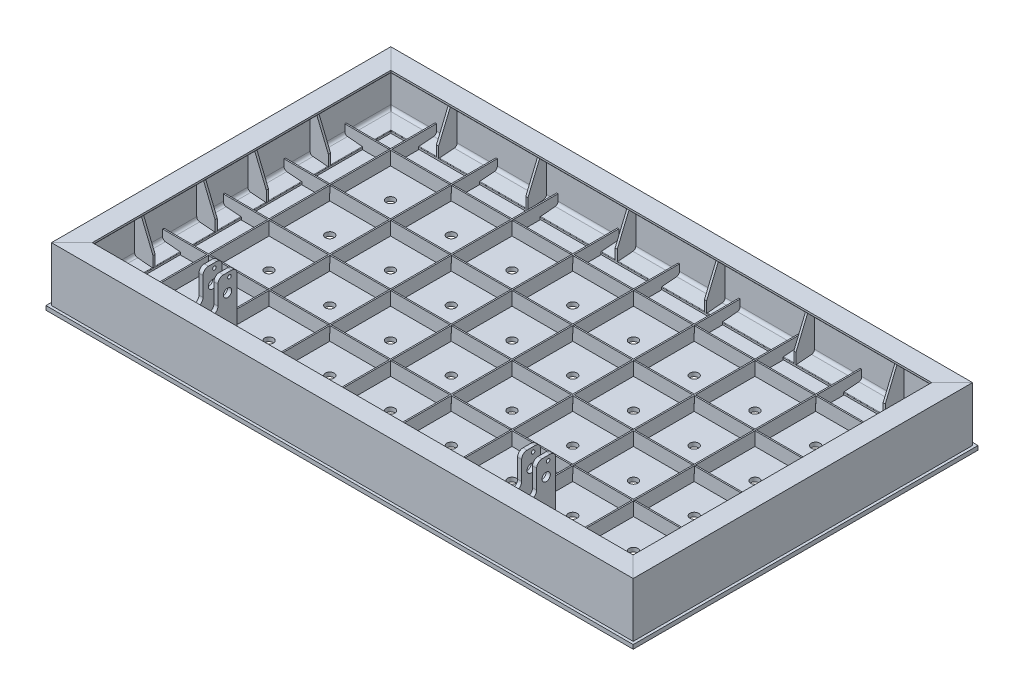
from build123d import *

# Parameters (mm, degrees)
UPN_200X75_SLDLFP_1_DEPTH      = 1660.600093633
UPN_200X75_SLDLFP_1_DEPTH_BACK = 414.600093633
UPN_200X75_SLDLFP_1_2_DEPTH    = 2965.200187266
UPN_200X75_SLDLFP_1_3_DEPTH    = 2075.200187266
UPN_200X75_SLDLFP_1_4_DEPTH    = 2965.200187266
ESQUISSE14_W                   = 5
ESQUISSE14_H                   = 50
GRAND_PLAT_50_5_DEPTH          = 2115
GRAND_PLAT_50_5_2_DEPTH        = 2115
GRAND_PLAT_50_5_3_DEPTH        = 2115
GRAND_PLAT_50_5_4_DEPTH        = 2115
GRAND_PLAT_50_5_5_DEPTH        = 2115
ENL_V_MAT_EXTRU_1_DEPTH        = 2115
ENL_V_MAT_EXTRU_1_DEPTH_BACK   = 2115
ENL_V_MAT_EXTRU_2_DEPTH        = 2115
ENL_V_MAT_EXTRU_2_DEPTH_BACK   = 2115
ESQUISSE17_W                   = 5
ESQUISSE17_H                   = 50
PITIT_PLAT_DE_50_5_DEPTH       = 1225
PITIT_PLAT_DE_50_5_2_DEPTH     = 1225
PITIT_PLAT_DE_50_5_3_DEPTH     = 1225
PITIT_PLAT_DE_50_5_4_DEPTH     = 1225
PITIT_PLAT_DE_50_5_5_DEPTH     = 1225
PITIT_PLAT_DE_50_5_6_DEPTH     = 1225
PITIT_PLAT_DE_50_5_7_DEPTH     = 1225
PITIT_PLAT_DE_50_5_8_DEPTH     = 1225
PITIT_PLAT_DE_50_5_9_DEPTH     = 1225
ENL_V_MAT_EXTRU_3_DEPTH        = 1225
ENL_V_MAT_EXTRU_3_DEPTH_BACK   = 1575
ESQUISSE19_W                   = 6
ESQUISSE19_H                   = 26
ENL_V_MAT_EXTRU_4_DEPTH        = 1575
ENL_V_MAT_EXTRU_4_DEPTH_BACK   = 1575
ESQUISSE20_W                   = 6
ESQUISSE20_H                   = 26
ENL_V_MAT_EXTRU_5_DEPTH        = 1575
ENL_V_MAT_EXTRU_5_DEPTH_BACK   = 1575
ESQUISSE21_W                   = 2156
ESQUISSE21_H                   = 1266
BOSS_EXTRU_4_DEPTH             = 15
ESQUISSE22_R                   = 16
ENL_V_MAT_EXTRU_6_DEPTH        = 15
BOSS_EXTRU_5_DEPTH             = 8
R_P_TITION_LIN_AIRE1_COUNT     = 3
R_P_TITION_LIN_AIRE1_PITCH     = 328
R_P_TITION_LIN_AIRE2_COUNT     = 4
R_P_TITION_LIN_AIRE2_PITCH     = 328
BOSS_EXTRU_7_DEPTH             = 8
R_P_TITION_LIN_AIRE6_COUNT     = 2
R_P_TITION_LIN_AIRE6_PITCH     = 228
ESQUISSE27_R                   = 15.25
ESQUISSE27_R_2                 = 6.5
BOSS_EXTRU_8_DEPTH             = 15
R_P_TITION_LIN_AIRE7_COUNT     = 2
R_P_TITION_LIN_AIRE7_PITCH     = 55


with BuildPart() as part:
    # Esquisse11 → Upn 200X75 SLDLFP(1) (new, two sides)
    with BuildSketch(Plane(origin=(1068, -200, 623), x_dir=(-1, 0, 0), z_dir=(0, 0, -1))) as upn_200x75_sldlfp_1_sk:
        with BuildLine():
            Line((0, 0), (75, 0))
            Line((75, 0), (75, 6.574620799))
            ThreePointArc((75, 6.574620799), (74.471012242, 7.929656954), (73.163877017, 8.567895572))
            Line((73.163877017, 8.567895572), (19.057707151, 13.016232475))
            ThreePointArc((19.057707151, 13.016232475), (11.541679606, 16.686104529), (8.5, 24.477562424))
            Line((8.5, 24.477562424), (8.5, 175.522437576))
            ThreePointArc((8.5, 175.522437576), (11.541679606, 183.313895471), (19.057707151, 186.983767525))
            Line((19.057707151, 186.983767525), (73.163877017, 191.432104428))
            ThreePointArc((73.163877017, 191.432104428), (74.471012242, 192.070343046), (75, 193.425379201))
            Line((75, 193.425379201), (75, 200))
            Line((75, 200), (0, 200))
            Line((0, 200), (0, 0))
        make_face()
    extrude(amount=UPN_200X75_SLDLFP_1_DEPTH)
    extrude(upn_200x75_sldlfp_1_sk.sketch, amount=-UPN_200X75_SLDLFP_1_DEPTH_BACK)

    # Upn 200X75 SLDLFP(1) mitre 1
    split(bisect_by=Plane(origin=(1068, 0, 623), x_dir=(0, 1, 0), z_dir=(0.707106781, 0, -0.707106781)), keep=Keep.TOP)

    # Upn 200X75 SLDLFP(1) mitre 2
    split(bisect_by=Plane(origin=(1068, 0, -623), x_dir=(0, 1, 0), z_dir=(0.707106781, 0, 0.707106781)), keep=Keep.TOP)


with BuildPart() as body_2:
    # Esquisse11 on segment 2 (carried to segment 2) → Upn 200X75 SLDLFP_1 2 (new body)
    with BuildSketch(Plane(origin=(1482.600093633, -200, -623), x_dir=(0, 0, 1), z_dir=(-1, 0, 0))):
        with BuildLine():
            Line((0, 0), (75, 0))
            Line((75, 0), (75, 6.574620799))
            ThreePointArc((75, 6.574620799), (74.471012242, 7.929656954), (73.163877017, 8.567895572))
            Line((73.163877017, 8.567895572), (19.057707151, 13.016232475))
            ThreePointArc((19.057707151, 13.016232475), (11.541679606, 16.686104529), (8.5, 24.477562424))
            Line((8.5, 24.477562424), (8.5, 175.522437576))
            ThreePointArc((8.5, 175.522437576), (11.541679606, 183.313895471), (19.057707151, 186.983767525))
            Line((19.057707151, 186.983767525), (73.163877017, 191.432104428))
            ThreePointArc((73.163877017, 191.432104428), (74.471012242, 192.070343046), (75, 193.425379201))
            Line((75, 193.425379201), (75, 200))
            Line((75, 200), (0, 200))
            Line((0, 200), (0, 0))
        make_face()
    extrude(amount=UPN_200X75_SLDLFP_1_2_DEPTH)

    # Upn 200X75 SLDLFP_1 2 mitre 1
    split(bisect_by=Plane(origin=(-1068, 0, -623), x_dir=(0, 1, 0), z_dir=(0.707106781, 0, -0.707106781)), keep=Keep.TOP)

    # Upn 200X75 SLDLFP_1 2 mitre 2
    split(bisect_by=Plane(origin=(1068, 0, -623), x_dir=(0, -1, 0), z_dir=(-0.707106781, 0, -0.707106781)), keep=Keep.TOP)


with BuildPart() as body_3:
    # Esquisse11 on segment 3 (carried to segment 3) → Upn 200X75 SLDLFP_1 3 (new body)
    with BuildSketch(Plane(origin=(-1068, -200, -1037.600093633), x_dir=(1, 0, 0), z_dir=(0, 0, 1))):
        with BuildLine():
            Line((0, 0), (75, 0))
            Line((75, 0), (75, 6.574620799))
            ThreePointArc((75, 6.574620799), (74.471012242, 7.929656954), (73.163877017, 8.567895572))
            Line((73.163877017, 8.567895572), (19.057707151, 13.016232475))
            ThreePointArc((19.057707151, 13.016232475), (11.541679606, 16.686104529), (8.5, 24.477562424))
            Line((8.5, 24.477562424), (8.5, 175.522437576))
            ThreePointArc((8.5, 175.522437576), (11.541679606, 183.313895471), (19.057707151, 186.983767525))
            Line((19.057707151, 186.983767525), (73.163877017, 191.432104428))
            ThreePointArc((73.163877017, 191.432104428), (74.471012242, 192.070343046), (75, 193.425379201))
            Line((75, 193.425379201), (75, 200))
            Line((75, 200), (0, 200))
            Line((0, 200), (0, 0))
        make_face()
    extrude(amount=UPN_200X75_SLDLFP_1_3_DEPTH)

    # Upn 200X75 SLDLFP_1 3 mitre 1
    split(bisect_by=Plane(origin=(-1068, 0, 623), x_dir=(0, -1, 0), z_dir=(-0.707106781, 0, -0.707106781)), keep=Keep.TOP)

    # Upn 200X75 SLDLFP_1 3 mitre 2
    split(bisect_by=Plane(origin=(-1068, 0, -623), x_dir=(0, -1, 0), z_dir=(-0.707106781, 0, 0.707106781)), keep=Keep.TOP)


with BuildPart() as body_4:
    # Esquisse11 on segment 4 (carried to segment 4) → Upn 200X75 SLDLFP_1 4 (new body)
    with BuildSketch(Plane(origin=(-1482.600093633, -200, 623), x_dir=(0, 0, -1), z_dir=(1, 0, 0))):
        with BuildLine():
            Line((0, 0), (75, 0))
            Line((75, 0), (75, 6.574620799))
            ThreePointArc((75, 6.574620799), (74.471012242, 7.929656954), (73.163877017, 8.567895572))
            Line((73.163877017, 8.567895572), (19.057707151, 13.016232475))
            ThreePointArc((19.057707151, 13.016232475), (11.541679606, 16.686104529), (8.5, 24.477562424))
            Line((8.5, 24.477562424), (8.5, 175.522437576))
            ThreePointArc((8.5, 175.522437576), (11.541679606, 183.313895471), (19.057707151, 186.983767525))
            Line((19.057707151, 186.983767525), (73.163877017, 191.432104428))
            ThreePointArc((73.163877017, 191.432104428), (74.471012242, 192.070343046), (75, 193.425379201))
            Line((75, 193.425379201), (75, 200))
            Line((75, 200), (0, 200))
            Line((0, 200), (0, 0))
        make_face()
    extrude(amount=UPN_200X75_SLDLFP_1_4_DEPTH)

    # Upn 200X75 SLDLFP_1 4 mitre 1
    split(bisect_by=Plane(origin=(-1068, 0, 623), x_dir=(0, 1, 0), z_dir=(0.707106781, 0, 0.707106781)), keep=Keep.TOP)

    # Upn 200X75 SLDLFP_1 4 mitre 2
    split(bisect_by=Plane(origin=(1068, 0, 623), x_dir=(0, -1, 0), z_dir=(-0.707106781, 0, 0.707106781)), keep=Keep.TOP)


with BuildPart() as body_5:
    # Esquisse14 → grand plat 50/5 (new body)
    with BuildSketch(Plane(origin=(-1057.5, 0, 0), x_dir=(0, 0, -1), z_dir=(1, 0, 0))):
        with Locations((446, -175)):
            Rectangle(ESQUISSE14_W, ESQUISSE14_H)
    extrude(amount=GRAND_PLAT_50_5_DEPTH)


with BuildPart() as body_6:
    # Esquisse14 → grand plat 50_5 2 (new body)
    with BuildSketch(Plane(origin=(-1057.5, 0, 0), x_dir=(0, 0, -1), z_dir=(1, 0, 0))):
        with Locations((0, -175)):
            Rectangle(ESQUISSE14_W, ESQUISSE14_H)
    extrude(amount=GRAND_PLAT_50_5_2_DEPTH)


with BuildPart() as body_7:
    # Esquisse14 → grand plat 50_5 3 (new body)
    with BuildSketch(Plane(origin=(-1057.5, 0, 0), x_dir=(0, 0, -1), z_dir=(1, 0, 0))):
        with Locations((-223, -175)):
            Rectangle(ESQUISSE14_W, ESQUISSE14_H)
    extrude(amount=GRAND_PLAT_50_5_3_DEPTH)


with BuildPart() as body_8:
    # Esquisse14 → grand plat 50_5 4 (new body)
    with BuildSketch(Plane(origin=(-1057.5, 0, 0), x_dir=(0, 0, -1), z_dir=(1, 0, 0))):
        with Locations((-446, -175)):
            Rectangle(ESQUISSE14_W, ESQUISSE14_H)
    extrude(amount=GRAND_PLAT_50_5_4_DEPTH)


with BuildPart() as body_9:
    # Esquisse14 → grand plat 50_5 5 (new body)
    with BuildSketch(Plane(origin=(-1057.5, 0, 0), x_dir=(0, 0, -1), z_dir=(1, 0, 0))):
        with Locations((223, -175)):
            Rectangle(ESQUISSE14_W, ESQUISSE14_H)
    extrude(amount=GRAND_PLAT_50_5_5_DEPTH)


with BuildPart() as enl_v_mat_extru_1_tool:
    # Esquisse15 → Enlèv. mat.-Extru.1 (new, two sides)
    with BuildSketch(Plane(origin=(0, 0, -2.5), x_dir=(-1, 0, 0), z_dir=(0, 0, -1))) as enl_v_mat_extru_1_sk:
        with BuildLine():
            Line((991.5, -200), (991.5, -190.201322727))
            Line((991.5, -190.201322727), (1046.942292849, -185.643136519))
            ThreePointArc((1046.942292849, -185.643136519), (1054.458320394, -181.973264464), (1057.5, -174.18180657))
            Line((1057.5, -174.18180657), (1057.5, -200))
            Line((1057.5, -200), (991.5, -200))
        make_face()
    extrude(amount=ENL_V_MAT_EXTRU_1_DEPTH)
    extrude(enl_v_mat_extru_1_sk.sketch, amount=-ENL_V_MAT_EXTRU_1_DEPTH_BACK)


with BuildPart() as body_8_1:
    add(body_8.part)

    # Enlèv. mat.-Extru.1: cut by enl_v_mat_extru_1_tool
    add(enl_v_mat_extru_1_tool.part, mode=Mode.SUBTRACT)


with BuildPart() as body_7_1:
    add(body_7.part)

    # Enlèv. mat.-Extru.1: cut by enl_v_mat_extru_1_tool
    add(enl_v_mat_extru_1_tool.part, mode=Mode.SUBTRACT)


with BuildPart() as body_6_1:
    add(body_6.part)

    # Enlèv. mat.-Extru.1: cut by enl_v_mat_extru_1_tool
    add(enl_v_mat_extru_1_tool.part, mode=Mode.SUBTRACT)


with BuildPart() as body_9_1:
    add(body_9.part)

    # Enlèv. mat.-Extru.1: cut by enl_v_mat_extru_1_tool
    add(enl_v_mat_extru_1_tool.part, mode=Mode.SUBTRACT)


with BuildPart() as body_5_1:
    add(body_5.part)

    # Enlèv. mat.-Extru.1: cut by enl_v_mat_extru_1_tool
    add(enl_v_mat_extru_1_tool.part, mode=Mode.SUBTRACT)


with BuildPart() as enl_v_mat_extru_2_tool:
    # Esquisse16 → Enlèv. mat.-Extru.2 (new, two sides)
    with BuildSketch(Plane(origin=(0, 0, 220.5), x_dir=(-1, 0, 0), z_dir=(0, 0, -1))) as enl_v_mat_extru_2_sk:
        with BuildLine():
            Line((-991.5, -200), (-991.5, -190.201322727))
            Line((-991.5, -190.201322727), (-1046.942292849, -185.643136519))
            ThreePointArc((-1046.942292849, -185.643136519), (-1054.458320394, -181.973264464), (-1057.5, -174.18180657))
            Line((-1057.5, -174.18180657), (-1057.5, -200))
            Line((-1057.5, -200), (-991.5, -200))
        make_face()
    extrude(amount=ENL_V_MAT_EXTRU_2_DEPTH)
    extrude(enl_v_mat_extru_2_sk.sketch, amount=-ENL_V_MAT_EXTRU_2_DEPTH_BACK)


with BuildPart() as body_8_2:
    add(body_8_1.part)

    # Enlèv. mat.-Extru.2: cut by enl_v_mat_extru_2_tool
    add(enl_v_mat_extru_2_tool.part, mode=Mode.SUBTRACT)


with BuildPart() as body_7_2:
    add(body_7_1.part)

    # Enlèv. mat.-Extru.2: cut by enl_v_mat_extru_2_tool
    add(enl_v_mat_extru_2_tool.part, mode=Mode.SUBTRACT)


with BuildPart() as body_6_2:
    add(body_6_1.part)

    # Enlèv. mat.-Extru.2: cut by enl_v_mat_extru_2_tool
    add(enl_v_mat_extru_2_tool.part, mode=Mode.SUBTRACT)


with BuildPart() as body_9_2:
    add(body_9_1.part)

    # Enlèv. mat.-Extru.2: cut by enl_v_mat_extru_2_tool
    add(enl_v_mat_extru_2_tool.part, mode=Mode.SUBTRACT)


with BuildPart() as body_5_2:
    add(body_5_1.part)

    # Enlèv. mat.-Extru.2: cut by enl_v_mat_extru_2_tool
    add(enl_v_mat_extru_2_tool.part, mode=Mode.SUBTRACT)


with BuildPart() as body_10:
    # Esquisse17 → pitit plat de 50/5 (new body)
    with BuildSketch(Plane(origin=(0, 0, 612.5), x_dir=(-1, 0, 0), z_dir=(0, 0, -1))):
        with Locations((223, -175)):
            Rectangle(ESQUISSE17_W, ESQUISSE17_H)
    extrude(amount=PITIT_PLAT_DE_50_5_DEPTH)


with BuildPart() as body_11:
    # Esquisse17 → pitit plat de 50_5 2 (new body)
    with BuildSketch(Plane(origin=(0, 0, 612.5), x_dir=(-1, 0, 0), z_dir=(0, 0, -1))):
        with Locations((0, -175)):
            Rectangle(ESQUISSE17_W, ESQUISSE17_H)
    extrude(amount=PITIT_PLAT_DE_50_5_2_DEPTH)


with BuildPart() as body_12:
    # Esquisse17 → pitit plat de 50_5 3 (new body)
    with BuildSketch(Plane(origin=(0, 0, 612.5), x_dir=(-1, 0, 0), z_dir=(0, 0, -1))):
        with Locations((446, -175)):
            Rectangle(ESQUISSE17_W, ESQUISSE17_H)
    extrude(amount=PITIT_PLAT_DE_50_5_3_DEPTH)


with BuildPart() as body_13:
    # Esquisse17 → pitit plat de 50_5 4 (new body)
    with BuildSketch(Plane(origin=(0, 0, 612.5), x_dir=(-1, 0, 0), z_dir=(0, 0, -1))):
        with Locations((669, -175)):
            Rectangle(ESQUISSE17_W, ESQUISSE17_H)
    extrude(amount=PITIT_PLAT_DE_50_5_4_DEPTH)


with BuildPart() as body_14:
    # Esquisse17 → pitit plat de 50_5 5 (new body)
    with BuildSketch(Plane(origin=(0, 0, 612.5), x_dir=(-1, 0, 0), z_dir=(0, 0, -1))):
        with Locations((892, -175)):
            Rectangle(ESQUISSE17_W, ESQUISSE17_H)
    extrude(amount=PITIT_PLAT_DE_50_5_5_DEPTH)


with BuildPart() as body_15:
    # Esquisse17 → pitit plat de 50_5 6 (new body)
    with BuildSketch(Plane(origin=(0, 0, 612.5), x_dir=(-1, 0, 0), z_dir=(0, 0, -1))):
        with Locations((-223, -175)):
            Rectangle(ESQUISSE17_W, ESQUISSE17_H)
    extrude(amount=PITIT_PLAT_DE_50_5_6_DEPTH)


with BuildPart() as body_16:
    # Esquisse17 → pitit plat de 50_5 7 (new body)
    with BuildSketch(Plane(origin=(0, 0, 612.5), x_dir=(-1, 0, 0), z_dir=(0, 0, -1))):
        with Locations((-446, -175)):
            Rectangle(ESQUISSE17_W, ESQUISSE17_H)
    extrude(amount=PITIT_PLAT_DE_50_5_7_DEPTH)


with BuildPart() as body_17:
    # Esquisse17 → pitit plat de 50_5 8 (new body)
    with BuildSketch(Plane(origin=(0, 0, 612.5), x_dir=(-1, 0, 0), z_dir=(0, 0, -1))):
        with Locations((-669, -175)):
            Rectangle(ESQUISSE17_W, ESQUISSE17_H)
    extrude(amount=PITIT_PLAT_DE_50_5_8_DEPTH)


with BuildPart() as body_18:
    # Esquisse17 → pitit plat de 50_5 9 (new body)
    with BuildSketch(Plane(origin=(0, 0, 612.5), x_dir=(-1, 0, 0), z_dir=(0, 0, -1))):
        with Locations((-892, -175)):
            Rectangle(ESQUISSE17_W, ESQUISSE17_H)
    extrude(amount=PITIT_PLAT_DE_50_5_9_DEPTH)


with BuildPart() as enl_v_mat_extru_3_tool:
    # Esquisse18 → Enlèv. mat.-Extru.3 (new, two sides)
    with BuildSketch(Plane.ZY.offset(448.5)) as enl_v_mat_extru_3_sk:
        with BuildLine():
            Line((-546.5, -200), (-546.5, -192.043640712))
            ThreePointArc((-546.5, -192.043640712), (-547.028987758, -190.688604557), (-548.336122983, -190.050365939))
            Line((-548.336122983, -190.050365939), (-601.942292849, -185.643136519))
            ThreePointArc((-601.942292849, -185.643136519), (-609.458320394, -181.973264464), (-612.5, -174.18180657))
            Line((-612.5, -174.18180657), (-612.5, -200))
            Line((-612.5, -200), (-546.5, -200))
        make_face()
        with BuildLine():
            Line((545.373523666, -200), (545.373523666, -190.716236027))
            ThreePointArc((545.373523666, -190.716236027), (545.902511424, -189.361199871), (547.209646649, -188.722961253))
            Line((547.209646649, -188.722961253), (601.942292849, -184.22311862))
            ThreePointArc((601.942292849, -184.22311862), (609.458320394, -180.553246566), (612.5, -172.761788672))
            Line((612.5, -172.761788672), (612.5, -200))
            Line((612.5, -200), (545.373523666, -200))
        make_face()
    extrude(amount=ENL_V_MAT_EXTRU_3_DEPTH)
    extrude(enl_v_mat_extru_3_sk.sketch, amount=-ENL_V_MAT_EXTRU_3_DEPTH_BACK)


with BuildPart() as body_18_1:
    add(body_18.part)

    # Enlèv. mat.-Extru.3: cut by enl_v_mat_extru_3_tool
    add(enl_v_mat_extru_3_tool.part, mode=Mode.SUBTRACT)


with BuildPart() as body_17_1:
    add(body_17.part)

    # Enlèv. mat.-Extru.3: cut by enl_v_mat_extru_3_tool
    add(enl_v_mat_extru_3_tool.part, mode=Mode.SUBTRACT)


with BuildPart() as body_16_1:
    add(body_16.part)

    # Enlèv. mat.-Extru.3: cut by enl_v_mat_extru_3_tool
    add(enl_v_mat_extru_3_tool.part, mode=Mode.SUBTRACT)


with BuildPart() as body_15_1:
    add(body_15.part)

    # Enlèv. mat.-Extru.3: cut by enl_v_mat_extru_3_tool
    add(enl_v_mat_extru_3_tool.part, mode=Mode.SUBTRACT)


with BuildPart() as body_11_1:
    add(body_11.part)

    # Enlèv. mat.-Extru.3: cut by enl_v_mat_extru_3_tool
    add(enl_v_mat_extru_3_tool.part, mode=Mode.SUBTRACT)


with BuildPart() as body_10_1:
    add(body_10.part)

    # Enlèv. mat.-Extru.3: cut by enl_v_mat_extru_3_tool
    add(enl_v_mat_extru_3_tool.part, mode=Mode.SUBTRACT)


with BuildPart() as body_12_1:
    add(body_12.part)

    # Enlèv. mat.-Extru.3: cut by enl_v_mat_extru_3_tool
    add(enl_v_mat_extru_3_tool.part, mode=Mode.SUBTRACT)


with BuildPart() as body_13_1:
    add(body_13.part)

    # Enlèv. mat.-Extru.3: cut by enl_v_mat_extru_3_tool
    add(enl_v_mat_extru_3_tool.part, mode=Mode.SUBTRACT)


with BuildPart() as body_14_1:
    add(body_14.part)

    # Enlèv. mat.-Extru.3: cut by enl_v_mat_extru_3_tool
    add(enl_v_mat_extru_3_tool.part, mode=Mode.SUBTRACT)


with BuildPart() as enl_v_mat_extru_4_tool:
    # Esquisse19 → Enlèv. mat.-Extru.4 (new, two sides)
    with BuildSketch(Plane.XY.offset(2.5)) as enl_v_mat_extru_4_sk:
        with Locations((-892, -163)):
            Rectangle(ESQUISSE19_W, ESQUISSE19_H)
        with Locations((-669, -163)):
            Rectangle(ESQUISSE19_W, ESQUISSE19_H)
        with Locations((-446, -163)):
            Rectangle(ESQUISSE19_W, ESQUISSE19_H)
        with Locations((-223, -163)):
            Rectangle(ESQUISSE19_W, ESQUISSE19_H)
        with Locations((0, -163)):
            Rectangle(ESQUISSE19_W, ESQUISSE19_H)
        with Locations((223, -163)):
            Rectangle(ESQUISSE19_W, ESQUISSE19_H)
        with Locations((446, -163)):
            Rectangle(ESQUISSE19_W, ESQUISSE19_H)
        with Locations((669, -163)):
            Rectangle(ESQUISSE19_W, ESQUISSE19_H)
        with Locations((892, -163)):
            Rectangle(ESQUISSE19_W, ESQUISSE19_H)
    extrude(amount=ENL_V_MAT_EXTRU_4_DEPTH)
    extrude(enl_v_mat_extru_4_sk.sketch, amount=-ENL_V_MAT_EXTRU_4_DEPTH_BACK)


with BuildPart() as body_5_3:
    add(body_5_2.part)

    # Enlèv. mat.-Extru.4: cut by enl_v_mat_extru_4_tool
    add(enl_v_mat_extru_4_tool.part, mode=Mode.SUBTRACT)


with BuildPart() as body_9_3:
    add(body_9_2.part)

    # Enlèv. mat.-Extru.4: cut by enl_v_mat_extru_4_tool
    add(enl_v_mat_extru_4_tool.part, mode=Mode.SUBTRACT)


with BuildPart() as body_6_3:
    add(body_6_2.part)

    # Enlèv. mat.-Extru.4: cut by enl_v_mat_extru_4_tool
    add(enl_v_mat_extru_4_tool.part, mode=Mode.SUBTRACT)


with BuildPart() as body_7_3:
    add(body_7_2.part)

    # Enlèv. mat.-Extru.4: cut by enl_v_mat_extru_4_tool
    add(enl_v_mat_extru_4_tool.part, mode=Mode.SUBTRACT)


with BuildPart() as body_8_3:
    add(body_8_2.part)

    # Enlèv. mat.-Extru.4: cut by enl_v_mat_extru_4_tool
    add(enl_v_mat_extru_4_tool.part, mode=Mode.SUBTRACT)


with BuildPart() as enl_v_mat_extru_5_tool:
    # Esquisse20 → Enlèv. mat.-Extru.5 (new, two sides)
    with BuildSketch(Plane.ZY.offset(448.5)) as enl_v_mat_extru_5_sk:
        with Locations((-446, -187)):
            Rectangle(ESQUISSE20_W, ESQUISSE20_H)
        with Locations((-223, -187)):
            Rectangle(ESQUISSE20_W, ESQUISSE20_H)
        with Locations((0, -187)):
            Rectangle(ESQUISSE20_W, ESQUISSE20_H)
        with Locations((223, -187)):
            Rectangle(ESQUISSE20_W, ESQUISSE20_H)
        with Locations((446, -187)):
            Rectangle(ESQUISSE20_W, ESQUISSE20_H)
    extrude(amount=ENL_V_MAT_EXTRU_5_DEPTH)
    extrude(enl_v_mat_extru_5_sk.sketch, amount=-ENL_V_MAT_EXTRU_5_DEPTH_BACK)


with BuildPart() as body_10_2:
    add(body_10_1.part)

    # Enlèv. mat.-Extru.5: cut by enl_v_mat_extru_5_tool
    add(enl_v_mat_extru_5_tool.part, mode=Mode.SUBTRACT)


with BuildPart() as body_11_2:
    add(body_11_1.part)

    # Enlèv. mat.-Extru.5: cut by enl_v_mat_extru_5_tool
    add(enl_v_mat_extru_5_tool.part, mode=Mode.SUBTRACT)


with BuildPart() as body_12_2:
    add(body_12_1.part)

    # Enlèv. mat.-Extru.5: cut by enl_v_mat_extru_5_tool
    add(enl_v_mat_extru_5_tool.part, mode=Mode.SUBTRACT)


with BuildPart() as body_13_2:
    add(body_13_1.part)

    # Enlèv. mat.-Extru.5: cut by enl_v_mat_extru_5_tool
    add(enl_v_mat_extru_5_tool.part, mode=Mode.SUBTRACT)


with BuildPart() as body_14_2:
    add(body_14_1.part)

    # Enlèv. mat.-Extru.5: cut by enl_v_mat_extru_5_tool
    add(enl_v_mat_extru_5_tool.part, mode=Mode.SUBTRACT)


with BuildPart() as body_15_2:
    add(body_15_1.part)

    # Enlèv. mat.-Extru.5: cut by enl_v_mat_extru_5_tool
    add(enl_v_mat_extru_5_tool.part, mode=Mode.SUBTRACT)


with BuildPart() as body_16_2:
    add(body_16_1.part)

    # Enlèv. mat.-Extru.5: cut by enl_v_mat_extru_5_tool
    add(enl_v_mat_extru_5_tool.part, mode=Mode.SUBTRACT)


with BuildPart() as body_17_2:
    add(body_17_1.part)

    # Enlèv. mat.-Extru.5: cut by enl_v_mat_extru_5_tool
    add(enl_v_mat_extru_5_tool.part, mode=Mode.SUBTRACT)


with BuildPart() as body_18_2:
    add(body_18_1.part)

    # Enlèv. mat.-Extru.5: cut by enl_v_mat_extru_5_tool
    add(enl_v_mat_extru_5_tool.part, mode=Mode.SUBTRACT)


with BuildPart() as body_19:
    # Esquisse21 → Boss.-Extru.4 (new body)
    with BuildSketch(Plane.XZ.offset(200)):
        Rectangle(ESQUISSE21_W, ESQUISSE21_H)
    extrude(amount=BOSS_EXTRU_4_DEPTH)

    # Esquisse22 → Enlèv. mat.-Extru.6 (cut)
    with BuildSketch(Plane.XZ.offset(215)):
        with Locations(Location((-780.5, 334.5, 0), (0, 0, 270))):
            Circle(ESQUISSE22_R)
        with Locations(Location((780.5, 334.5, 0), (0, 0, 270))):
            Circle(ESQUISSE22_R)
        with Locations(Location((-557.5, 334.5, 0), (0, 0, 270))):
            Circle(ESQUISSE22_R)
        with Locations(Location((-334.5, 334.5, 0), (0, 0, 270))):
            Circle(ESQUISSE22_R)
        with Locations(Location((-111.5, 334.5, 0), (0, 0, 270))):
            Circle(ESQUISSE22_R)
        with Locations(Location((111.5, 334.5, 0), (0, 0, 270))):
            Circle(ESQUISSE22_R)
        with Locations(Location((334.5, 334.5, 0), (0, 0, 270))):
            Circle(ESQUISSE22_R)
        with Locations(Location((557.5, 334.5, 0), (0, 0, 270))):
            Circle(ESQUISSE22_R)
        with Locations(Location((-780.5, 111.5, 0), (0, 0, 270))):
            Circle(ESQUISSE22_R)
        with Locations(Location((-557.5, 111.5, 0), (0, 0, 270))):
            Circle(ESQUISSE22_R)
        with Locations(Location((-334.5, 111.5, 0), (0, 0, 270))):
            Circle(ESQUISSE22_R)
        with Locations(Location((-111.5, 111.5, 0), (0, 0, 270))):
            Circle(ESQUISSE22_R)
        with Locations(Location((111.5, 111.5, 0), (0, 0, 270))):
            Circle(ESQUISSE22_R)
        with Locations(Location((334.5, 111.5, 0), (0, 0, 270))):
            Circle(ESQUISSE22_R)
        with Locations(Location((557.5, 111.5, 0), (0, 0, 270))):
            Circle(ESQUISSE22_R)
        with Locations(Location((780.5, 111.5, 0), (0, 0, 270))):
            Circle(ESQUISSE22_R)
        with Locations(Location((-780.5, -111.5, 0), (0, 0, 270))):
            Circle(ESQUISSE22_R)
        with Locations(Location((-557.5, -111.5, 0), (0, 0, 270))):
            Circle(ESQUISSE22_R)
        with Locations(Location((-334.5, -111.5, 0), (0, 0, 270))):
            Circle(ESQUISSE22_R)
        with Locations(Location((-111.5, -111.5, 0), (0, 0, 270))):
            Circle(ESQUISSE22_R)
        with Locations(Location((111.5, -111.5, 0), (0, 0, 270))):
            Circle(ESQUISSE22_R)
        with Locations(Location((334.5, -111.5, 0), (0, 0, 270))):
            Circle(ESQUISSE22_R)
        with Locations(Location((557.5, -111.5, 0), (0, 0, 270))):
            Circle(ESQUISSE22_R)
        with Locations(Location((780.5, -111.5, 0), (0, 0, 270))):
            Circle(ESQUISSE22_R)
        with Locations(Location((-780.5, -334.5, 0), (0, 0, 270))):
            Circle(ESQUISSE22_R)
        with Locations(Location((-557.5, -334.5, 0), (0, 0, 270))):
            Circle(ESQUISSE22_R)
        with Locations(Location((-334.5, -334.5, 0), (0, 0, 270))):
            Circle(ESQUISSE22_R)
        with Locations(Location((-111.5, -334.5, 0), (0, 0, 270))):
            Circle(ESQUISSE22_R)
        with Locations(Location((111.5, -334.5, 0), (0, 0, 270))):
            Circle(ESQUISSE22_R)
        with Locations(Location((334.5, -334.5, 0), (0, 0, 270))):
            Circle(ESQUISSE22_R)
        with Locations(Location((557.5, -334.5, 0), (0, 0, 270))):
            Circle(ESQUISSE22_R)
        with Locations(Location((780.5, -334.5, 0), (0, 0, 270))):
            Circle(ESQUISSE22_R)
    extrude(amount=-ENL_V_MAT_EXTRU_6_DEPTH, mode=Mode.SUBTRACT)


with BuildPart() as body_20:
    # Esquisse24 → Boss.-Extru.5 (new body)
    with BuildSketch(Plane(origin=(160, 0, 0), x_dir=(0, 0, -1), z_dir=(1, 0, 0))):
        with BuildLine():
            Line((-546.529467568, -191.703960989), (-604.401323595, -186.946028328))
            ThreePointArc((-604.401323595, -186.946028328), (-611.590567333, -183.435715928), (-614.5, -175.983017073))
            Line((-614.5, -175.983017073), (-614.5, -25))
            Line((-614.5, -25), (-599.509100795, -24.477562424))
            Line((-599.509100795, -24.477562424), (-546.529467568, -151.703960989))
            Line((-546.529467568, -151.703960989), (-546.529467568, -191.703960989))
        make_face()
    extrude(amount=BOSS_EXTRU_5_DEPTH)


with BuildPart() as r_p_tition_lin_aire1_1:
    # Répétition linéaire1: pattern copy
    add(body_20.part.moved(Location(Vector(1, 0, 0) * (1 * R_P_TITION_LIN_AIRE1_PITCH))))


with BuildPart() as r_p_tition_lin_aire1_2:
    # Répétition linéaire1: pattern copy
    add(body_20.part.moved(Location(Vector(1, 0, 0) * (2 * R_P_TITION_LIN_AIRE1_PITCH))))


with BuildPart() as r_p_tition_lin_aire2_1:
    # Répétition linéaire2: pattern copy
    add(body_20.part.moved(Location(Vector(-1, 0, 0) * (1 * R_P_TITION_LIN_AIRE2_PITCH))))


with BuildPart() as r_p_tition_lin_aire2_2:
    # Répétition linéaire2: pattern copy
    add(body_20.part.moved(Location(Vector(-1, 0, 0) * (2 * R_P_TITION_LIN_AIRE2_PITCH))))


with BuildPart() as r_p_tition_lin_aire2_3:
    # Répétition linéaire2: pattern copy
    add(body_20.part.moved(Location(Vector(-1, 0, 0) * (3 * R_P_TITION_LIN_AIRE2_PITCH))))


with BuildPart() as body_26:
    # Symétrie1: mirrored copy
    add(r_p_tition_lin_aire2_3.part.mirror(Plane.XY))


with BuildPart() as body_27:
    # Sym_trie1 2: mirrored copy
    add(r_p_tition_lin_aire2_2.part.mirror(Plane.XY))


with BuildPart() as body_28:
    # Sym_trie1 3: mirrored copy
    add(r_p_tition_lin_aire2_1.part.mirror(Plane.XY))


with BuildPart() as body_29:
    # Sym_trie1 4: mirrored copy
    add(body_20.part.mirror(Plane.XY))


with BuildPart() as body_30:
    # Sym_trie1 5: mirrored copy
    add(r_p_tition_lin_aire1_1.part.mirror(Plane.XY))


with BuildPart() as body_31:
    # Sym_trie1 6: mirrored copy
    add(r_p_tition_lin_aire1_2.part.mirror(Plane.XY))


with BuildPart() as body_32:
    # Esquisse26 → Boss.-Extru.7 (new body)
    with BuildSketch(Plane.XY.offset(90)):
        with BuildLine():
            Line((-1059.5, -24.477562424), (-1059.5, -175.983017073))
            ThreePointArc((-1059.5, -175.983017073), (-1056.590567333, -183.435715928), (-1049.401323595, -186.946028328))
            Line((-1049.401323595, -186.946028328), (-992.170584691, -191.651251567))
            Line((-992.170584691, -191.651251567), (-992.170584691, -151.651251567))
            Line((-992.170584691, -151.651251567), (-1044.5, -24.477562424))
            Line((-1044.5, -24.477562424), (-1059.5, -24.477562424))
        make_face()
    extrude(amount=BOSS_EXTRU_7_DEPTH)


with BuildPart() as r_p_tition_lin_aire6_1:
    # Répétition linéaire6: pattern copy
    add(body_32.part.moved(Location(Vector(0, 0, 1) * (1 * R_P_TITION_LIN_AIRE6_PITCH))))


with BuildPart() as body_34:
    # Symétrie3: mirrored copy
    add(body_32.part.mirror(Plane.XY))


with BuildPart() as body_35:
    # Sym_trie3 2: mirrored copy
    add(r_p_tition_lin_aire6_1.part.mirror(Plane.XY))


with BuildPart() as body_36:
    # Symétrie4: mirrored copy
    add(body_35.part.mirror(Plane(origin=(0, 0, 0), x_dir=(0, 0, 1), z_dir=(1, 0, 0))))


with BuildPart() as body_37:
    # Sym_trie4 2: mirrored copy
    add(body_34.part.mirror(Plane(origin=(0, 0, 0), x_dir=(0, 0, 1), z_dir=(1, 0, 0))))


with BuildPart() as body_38:
    # Sym_trie4 3: mirrored copy
    add(body_32.part.mirror(Plane(origin=(0, 0, 0), x_dir=(0, 0, 1), z_dir=(1, 0, 0))))


with BuildPart() as body_39:
    # Sym_trie4 4: mirrored copy
    add(r_p_tition_lin_aire6_1.part.mirror(Plane(origin=(0, 0, 0), x_dir=(0, 0, 1), z_dir=(1, 0, 0))))


with BuildPart() as body_40:
    # Esquisse27 → Boss.-Extru.8 (new body)
    with BuildSketch(Plane(origin=(550, 0, 0), x_dir=(0, 0, -1), z_dir=(1, 0, 0))):
        with BuildLine():
            Line((-544.373523666, -200), (-544.373523666, -187.952759049))
            Line((-544.373523666, -187.952759049), (-604.401323595, -183.017575533))
            ThreePointArc((-604.401323595, -183.017575533), (-611.590567333, -179.507263133), (-614.5, -172.054564278))
            Line((-614.5, -172.054564278), (-614.5, -25.020356886))
            ThreePointArc((-614.5, -25.020356886), (-611.590567333, -17.56765803), (-604.401323595, -14.057345631))
            Line((-604.401323595, -14.057345631), (-547.861229827, -9.408903758))
            ThreePointArc((-547.861229827, -9.408903758), (-534.789877576, -3.026517576), (-529.5, 10.523843979))
            Line((-529.5, 10.523843979), (-529.5, 80))
            ThreePointArc((-529.5, 80), (-523.642135624, 94.142135624), (-509.5, 100))
            Line((-509.5, 100), (-479.5, 100))
            ThreePointArc((-479.5, 100), (-465.357864376, 94.142135624), (-459.5, 80))
            Line((-459.5, 80), (-459.5, -200))
            Line((-459.5, -200), (-544.373523666, -200))
        make_face()
        with Locations((-494.5, 35)):
            Circle(ESQUISSE27_R, mode=Mode.SUBTRACT)
        with Locations((-487.5, 83)):
            Circle(ESQUISSE27_R_2, mode=Mode.SUBTRACT)
    extrude(amount=BOSS_EXTRU_8_DEPTH)


with BuildPart() as r_p_tition_lin_aire7_1:
    # Répétition linéaire7: pattern copy
    add(body_40.part.moved(Location(Vector(1, 0, 0) * (1 * R_P_TITION_LIN_AIRE7_PITCH))))


with BuildPart() as body_42:
    # Symétrie5: mirrored copy
    add(r_p_tition_lin_aire7_1.part.mirror(Plane(origin=(0, 0, 0), x_dir=(0, 0, 1), z_dir=(1, 0, 0))))


with BuildPart() as body_43:
    # Sym_trie5 2: mirrored copy
    add(body_40.part.mirror(Plane(origin=(0, 0, 0), x_dir=(0, 0, 1), z_dir=(1, 0, 0))))


solid = Compound([part.part, body_2.part, body_3.part, body_4.part, body_5_3.part, body_9_3.part, body_6_3.part, body_7_3.part, body_8_3.part, body_10_2.part, body_11_2.part, body_12_2.part, body_13_2.part, body_14_2.part, body_15_2.part, body_16_2.part, body_17_2.part, body_18_2.part, body_19.part, body_20.part, r_p_tition_lin_aire1_1.part, r_p_tition_lin_aire1_2.part, r_p_tition_lin_aire2_1.part, r_p_tition_lin_aire2_2.part, r_p_tition_lin_aire2_3.part, body_26.part, body_27.part, body_28.part, body_29.part, body_30.part, body_31.part, body_32.part, r_p_tition_lin_aire6_1.part, body_34.part, body_35.part, body_36.part, body_37.part, body_38.part, body_39.part, body_40.part, r_p_tition_lin_aire7_1.part, body_42.part, body_43.part])
